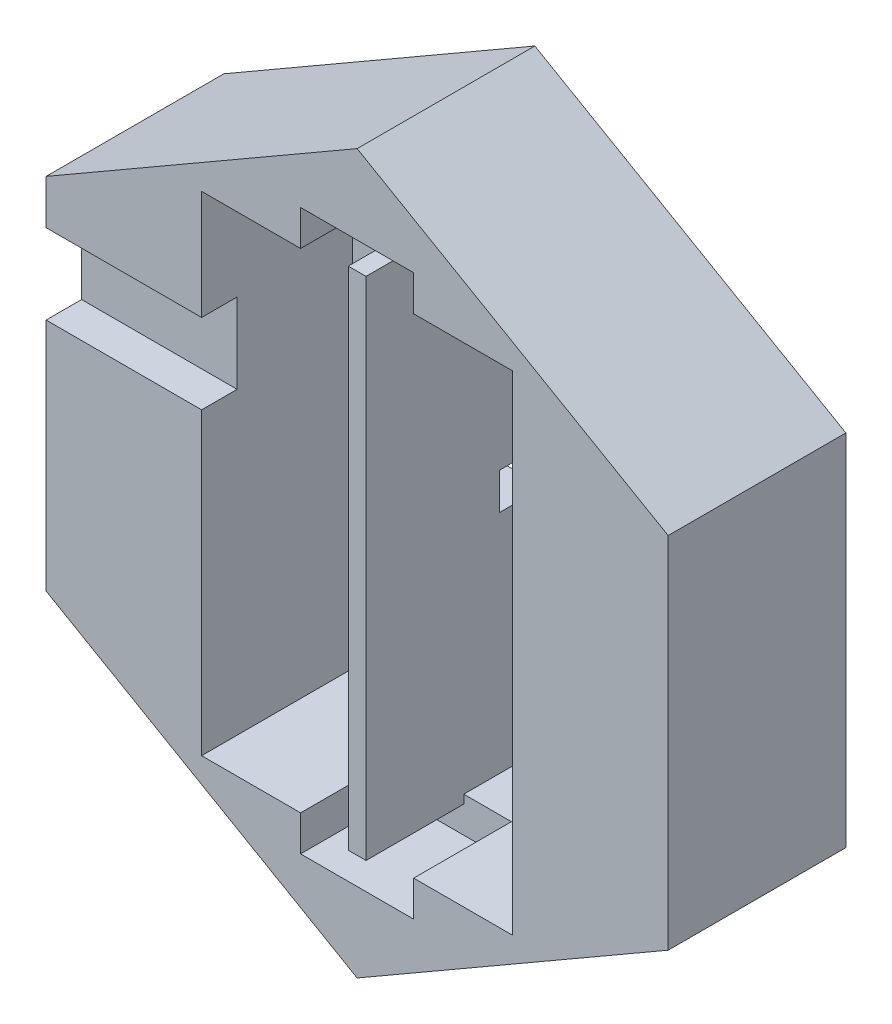
from build123d import *

# Parameters (mm, degrees)
BOSS_EXTRUDE1_DEPTH = 200
SKETCH2_W           = 165
SKETCH2_H           = 550
CUT_EXTRUDE1_DEPTH  = 170
CUT_EXTRUDE2_DEPTH  = 50
CUT_EXTRUDE5_DEPTH  = 110
SCALE1_SCALE        = 0.1
SKETCH7_W           = 4
SKETCH7_H           = 9
CUT_EXTRUDE6_DEPTH  = 17.5


with BuildPart() as part:
    # Sketch1 → Boss-Extrude1 (new body)
    with BuildSketch(Plane.XY):
        Polygon((0, 404.145188433), (-350, 202.072594216), (-350, -202.072594216), (0, -404.145188433), (350, -202.072594216), (350, 202.072594216), align=None)
    extrude(amount=BOSS_EXTRUDE1_DEPTH)

    # Sketch2 → Cut-Extrude1 (cut)
    with BuildSketch(Plane.XY.offset(200)):
        with Locations((-92.5, 0)):
            Rectangle(SKETCH2_W, SKETCH2_H)
        with Locations((92.5, 0)):
            Rectangle(SKETCH2_W, SKETCH2_H)
    extrude(amount=-CUT_EXTRUDE1_DEPTH, mode=Mode.SUBTRACT)

    # Sketch4 → Cut-Extrude2 (cut)
    with BuildSketch(Plane(origin=(0, 0, 0), x_dir=(-1, 0, 0), z_dir=(0, 0, -1))):
        with BuildLine():
            Line((-85, 20.592361582), (85, 20.592361582))
            ThreePointArc((85, 20.592361582), (105.592361582, 0), (85, -20.592361582))
            Line((85, -20.592361582), (-85, -20.592361582))
            ThreePointArc((-85, -20.592361582), (-105.592361582, 0), (-85, 20.592361582))
        make_face()
    extrude(amount=-CUT_EXTRUDE2_DEPTH, mode=Mode.SUBTRACT)

    # Sketch6 → Cut-Extrude5 (cut)
    with BuildSketch(Plane.XY.offset(200)):
        Polygon((-10, 275), (-10, 284.635017666), (10, 284.635017666), (10, 275), (63.624515443, 275), (63.624515443, 315), (-63.624515443, 315), (-63.624515443, 275), align=None)
        Polygon((-10, -275), (-63.624515443, -275), (-63.624515443, -315), (63.624515443, -315), (63.624515443, -275), (10, -275), (10, -284.635017666), (-10, -284.635017666), align=None)
    extrude(amount=-CUT_EXTRUDE5_DEPTH, mode=Mode.SUBTRACT)


with BuildPart() as part_1:
    # Scale1: scaled about (0, 0, 90.714754865)
    add(part.part.scale(SCALE1_SCALE).moved(Location((0, 0, 81.643279379))))

    # Sketch7 → Cut-Extrude6 (cut)
    with BuildSketch(Plane.ZY.offset(35)):
        with Locations((99.650437811, 10.707259422)):
            Rectangle(SKETCH7_W, SKETCH7_H)
    extrude(amount=-CUT_EXTRUDE6_DEPTH, mode=Mode.SUBTRACT)


solid = part_1.part
